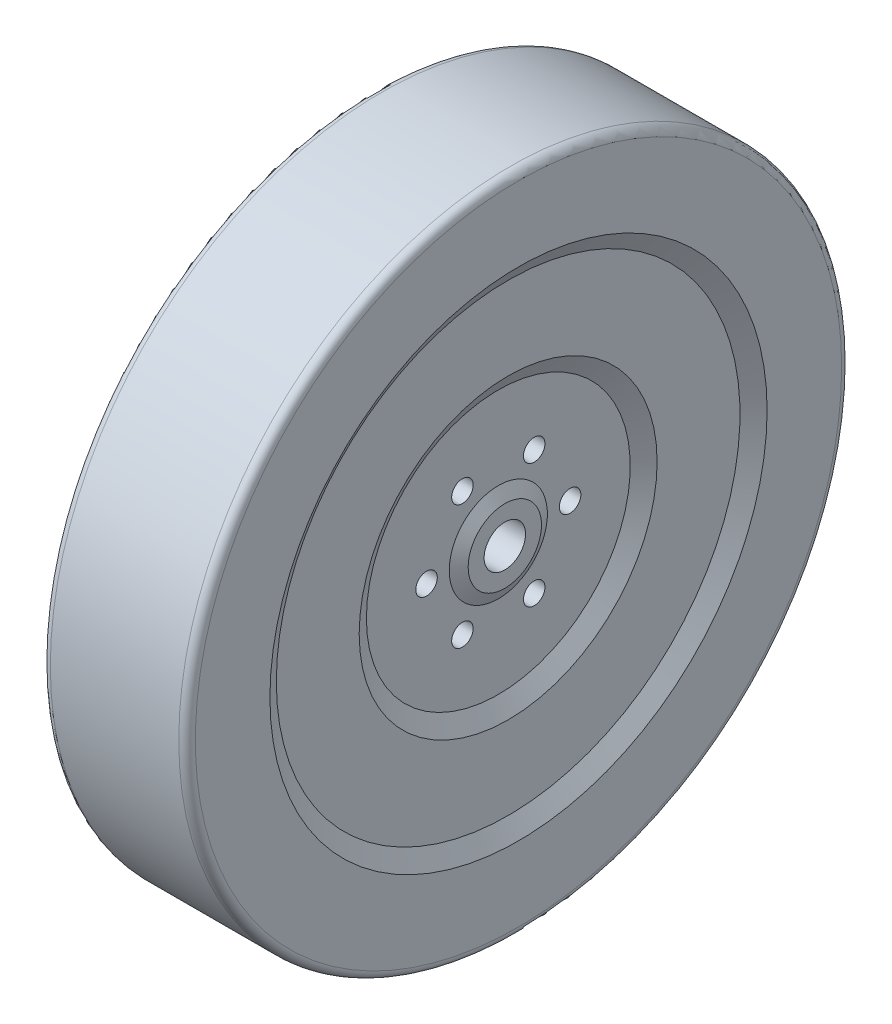
from build123d import *

# Parameters (mm, degrees)
SKETCH3_R          = 3.3
CUT_EXTRUDE1_DEPTH = 39.259
FILLET1_R          = 2.54


with BuildPart() as part:
    # Sketch2 → Revolve1 (revolve)
    with BuildSketch(Plane(origin=(0, 0, 0), x_dir=(1, 0, 0), z_dir=(0, 1, 0))):
        Polygon((22.225, -101.6), (22.225, -76.2), (19.05, -71.063365236), (19.05, -45.663365236), (16.034, -40.4395), (16.034, -15.0395), (18.034, -11.2395), (18.034, -6.35), (-18.034, -6.35), (-18.034, -11.2395), (-16.034, -15.0395), (-16.034, -40.4395), (-19.05, -45.663365236), (-19.05, -71.063365236), (-22.225, -76.2), (-22.225, -101.6), align=None)
    revolve(axis=Axis((0, 0, 0), (1, 0, 0)))

    # Sketch3 → Cut-Extrude1 (cut, through all)
    with BuildSketch(Plane(origin=(16.034, 0, 0), x_dir=(0, 0, -1), z_dir=(1, 0, 0))):
        with Locations((22, 0)):
            Circle(SKETCH3_R)
        with Locations((11, -19.052558883)):
            Circle(SKETCH3_R)
        with Locations((-11, -19.052558883)):
            Circle(SKETCH3_R)
        with Locations((-22, 0)):
            Circle(SKETCH3_R)
        with Locations((-11, 19.052558883)):
            Circle(SKETCH3_R)
        with Locations((11, 19.052558883)):
            Circle(SKETCH3_R)
    extrude(amount=-CUT_EXTRUDE1_DEPTH, mode=Mode.SUBTRACT)

    # Fillet1
    fillet1_edges = [part.edges().sort_by_distance(p)[0] for p in [
        (22.225, 0, -101.6),
        (-22.225, 0, -101.6),
    ]]
    fillet(fillet1_edges, radius=FILLET1_R)


solid = part.part
